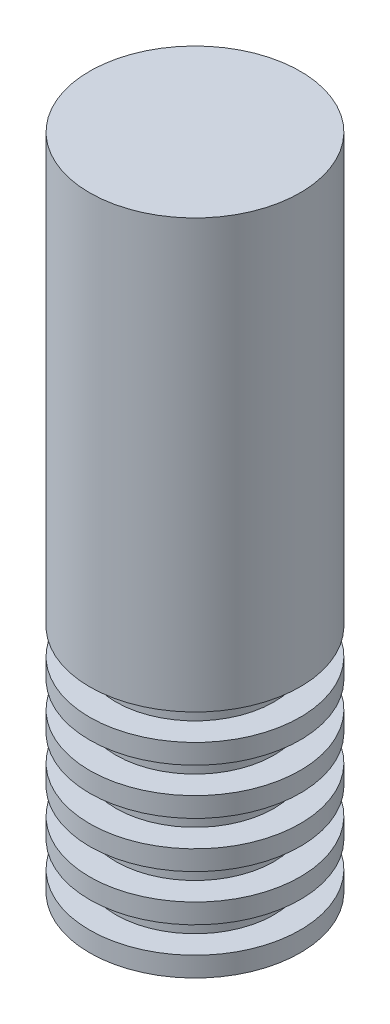
from build123d import *


with BuildPart() as part:
    # Croquis1 → Revolución1 (revolve)
    with BuildSketch(Plane.XY):
        Polygon((0, 50), (8, 50), (8, 17.5), (6, 17.5), (6, 15.5), (8, 15.5), (8, 14), (6, 14), (6, 12), (8, 12), (8, 10.5), (6, 10.5), (6, 8.5), (8, 8.5), (8, 7), (6, 7), (6, 5), (8, 5), (8, 3.5), (6, 3.5), (6, 1.5), (8, 1.5), (8, 0), (4, 0), (4, -2), (0, -2), (0, 0), align=None)
    revolve(axis=Axis((0, 68.764044944, 0), (0, -1, 0)))


solid = part.part
